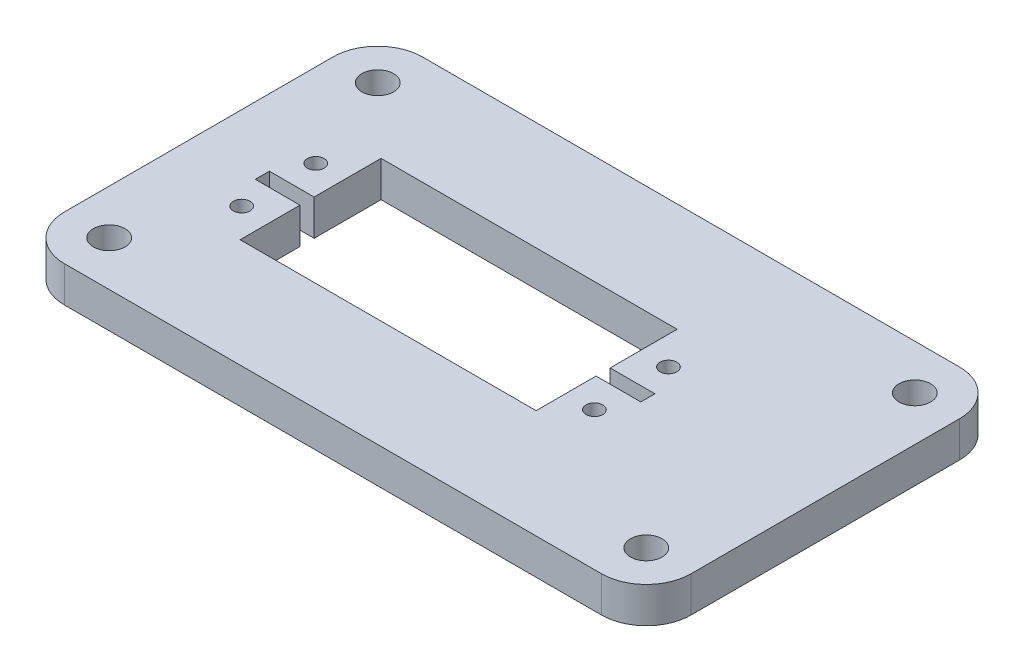
from build123d import *

# Parameters (mm, degrees)
SKETCH1_W                       = 88.9
SKETCH1_H                       = 50.8
SKETCH1_W_2                     = 42.0000176
SKETCH1_H_2                     = 20
BOSS_EXTRUDE1_DEPTH             = 5.08
F_3_32_0_09375_DIAMETER_HOLE1_D = 2.38125
SKETCH4_W                       = 6.35
SKETCH4_H                       = 2
CUT_EXTRUDE1_DEPTH              = 6.08
FILLET2_R                       = 6.35
F_8_CLEARANCE_HOLE1_D           = 4.4958


with BuildPart() as part:
    # Sketch1 → Boss-Extrude1 (new body)
    with BuildSketch(Plane(origin=(0, 0, 0), x_dir=(1, 0, 0), z_dir=(0, 1, 0))):
        with Locations((-44.45, -25.4)):
            Rectangle(SKETCH1_W, SKETCH1_H)
        with Locations((-52.0249912, -25.4)):
            Rectangle(SKETCH1_W_2, SKETCH1_H_2, mode=Mode.SUBTRACT)
    extrude(amount=BOSS_EXTRUDE1_DEPTH)

    # 3/32 (0.09375) Diameter Hole1 (through all)
    with Locations(Plane(origin=(0, 5.08, 0), x_dir=(1, 0, 0), z_dir=(0, 1, 0))):
        with Locations((-77.0439912, -31.15), (-77.0439912, -20.65), (-27.0059912, -31.15), (-27.0059912, -20.65)):
            Hole(F_3_32_0_09375_DIAMETER_HOLE1_D / 2)

    # Sketch4 → Cut-Extrude1 (cut, through all)
    with BuildSketch(Plane(origin=(0, 5.08, 0), x_dir=(1, 0, 0), z_dir=(0, 1, 0))):
        with Locations((-76.2, -25.9)):
            Rectangle(SKETCH4_W, SKETCH4_H)
        with Locations((-27.8499824, -25.9)):
            Rectangle(SKETCH4_W, SKETCH4_H)
    extrude(amount=-CUT_EXTRUDE1_DEPTH, mode=Mode.SUBTRACT)

    # Fillet2
    fillet2_edges = [part.edges().sort_by_distance(p)[0] for p in [
        (-88.9, 2.54, 0),
        (0, 2.54, 0),
        (0, 2.54, 50.8),
        (-88.9, 2.54, 50.8),
    ]]
    fillet(fillet2_edges, radius=FILLET2_R)

    # #8 Clearance Hole1 (through all)
    with Locations(Plane(origin=(0, 5.08, 0), x_dir=(1, 0, 0), z_dir=(0, 1, 0))):
        with Locations((-82.55, -6.35), (-82.55, -44.45), (-6.35, -6.35), (-6.35, -44.45)):
            Hole(F_8_CLEARANCE_HOLE1_D / 2)


solid = part.part
